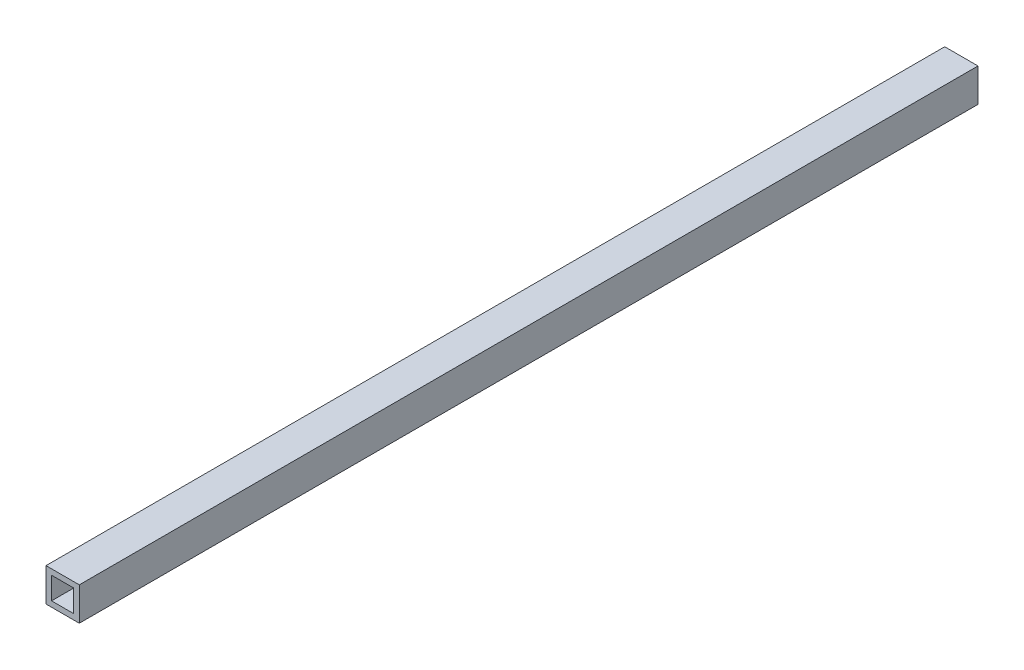
from build123d import *

# Parameters (mm, degrees)
SKETCH1_W           = 19.05
SKETCH1_H           = 19.05
BOSS_EXTRUDE1_DEPTH = 514.35
CUT_EXTRUDE1_REACH  = 516.35
SKETCH2_W           = 12.7
SKETCH2_H           = 12.7


with BuildPart() as part:
    # Sketch1 → Boss-Extrude1 (new body)
    with BuildSketch(Plane.XY):
        Rectangle(SKETCH1_W, SKETCH1_H)
    extrude(amount=-BOSS_EXTRUDE1_DEPTH)

    # Sketch2 → Cut-Extrude1 (cut, up to next)
    with BuildSketch(Plane.XY, mode=Mode.PRIVATE) as cut_extrude1_sk1:
        Rectangle(SKETCH2_W, SKETCH2_H)
    cut_extrude1_tool1 = extrude(cut_extrude1_sk1.sketch, amount=-CUT_EXTRUDE1_REACH, mode=Mode.PRIVATE) & part.part
    add(cut_extrude1_tool1.solids().sort_by_distance((0, 0, 0))[0], mode=Mode.SUBTRACT)


solid = part.part
